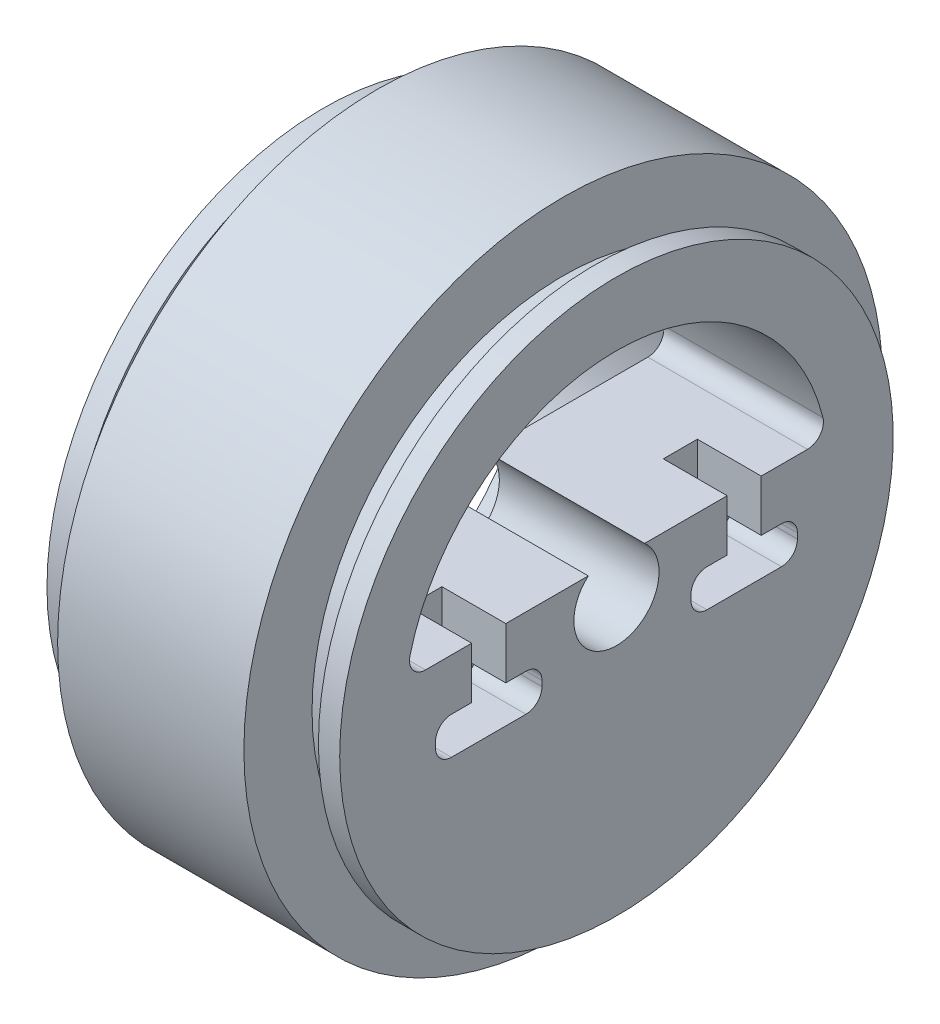
from build123d import *

# Parameters (mm, degrees)
EXTRUSION1_DEPTH = 28.5
EXTRUSION2_DEPTH = 6


with BuildPart() as part:
    # Esquisse1 → Révolution1 (revolve)
    with BuildSketch(Plane.XY):
        Polygon((-9.132382096, 20), (-9.132382096, 26), (-7.132382096, 26), (-7.132382096, 23.6), (-4.132382096, 23.6), (-4.132382096, 30), (13.367617904, 30), (13.367617904, 23.6), (16.367617904, 23.6), (16.367617904, 26), (18.367617904, 26), (18.367617904, 4), (3.367617904, 4), (3.367617904, 20), align=None)
    revolve(axis=Axis((3.367617904, 0, 0), (1, 0, 0)))

    # Esquisse2 → Extrusion1 (cut, through all)
    with BuildSketch(Plane(origin=(18.367617904, 0, 0), x_dir=(0, 0, -1), z_dir=(1, 0, 0))):
        with BuildLine():
            Line((17.944358445, 3), (-17.944358445, 3))
            ThreePointArc((-17.944358445, 3), (-19.127003214, 3.577312972), (-19.399306427, 4.864864865))
            ThreePointArc((-19.399306427, 4.864864865), (0, 20), (19.399306427, 4.864864865))
            ThreePointArc((19.399306427, 4.864864865), (19.127003214, 3.577312972), (17.944358445, 3))
        make_face()
    extrude(amount=-EXTRUSION1_DEPTH, mode=Mode.SUBTRACT)

    # Esquisse3 → Extrusion2 (cut)
    with BuildSketch(Plane(origin=(18.367617904, 0, 0), x_dir=(0, 0, -1), z_dir=(1, 0, 0))):
        with BuildLine():
            Line((-10.4, -1.829201479), (-10.4, 3.170798521))
            Line((-10.4, 3.170798521), (-13.6, 3.170798521))
            Line((-13.6, 3.170798521), (-13.6, -1.829201479))
            Line((-13.6, -1.829201479), (-15.5, -1.829201479))
            ThreePointArc((-15.5, -1.829201479), (-16.560660172, -2.268541307), (-17, -3.329201479))
            Line((-17, -3.329201479), (-17, -3.829201479))
            ThreePointArc((-17, -3.829201479), (-16.560660172, -4.889861651), (-15.5, -5.329201479))
            Line((-15.5, -5.329201479), (-8.5, -5.329201479))
            ThreePointArc((-8.5, -5.329201479), (-7.439339828, -4.889861651), (-7, -3.829201479))
            Line((-7, -3.829201479), (-7, -3.329201479))
            ThreePointArc((-7, -3.329201479), (-7.439339828, -2.268541307), (-8.5, -1.829201479))
            Line((-8.5, -1.829201479), (-10.4, -1.829201479))
        make_face()
        with BuildLine():
            Line((7, -3.329201479), (7, -3.829201479))
            ThreePointArc((7, -3.829201479), (7.439339828, -4.889861651), (8.5, -5.329201479))
            Line((8.5, -5.329201479), (15.5, -5.329201479))
            ThreePointArc((15.5, -5.329201479), (16.560660172, -4.889861651), (17, -3.829201479))
            Line((17, -3.829201479), (17, -3.329201479))
            ThreePointArc((17, -3.329201479), (16.560660172, -2.268541307), (15.5, -1.829201479))
            Line((15.5, -1.829201479), (13.6, -1.829201479))
            Line((13.6, -1.829201479), (13.6, 3.170798521))
            Line((13.6, 3.170798521), (10.4, 3.170798521))
            Line((10.4, 3.170798521), (10.4, -1.829201479))
            Line((10.4, -1.829201479), (8.5, -1.829201479))
            ThreePointArc((8.5, -1.829201479), (7.439339828, -2.268541307), (7, -3.329201479))
        make_face()
    extrude(amount=-EXTRUSION2_DEPTH, mode=Mode.SUBTRACT)


solid = part.part
